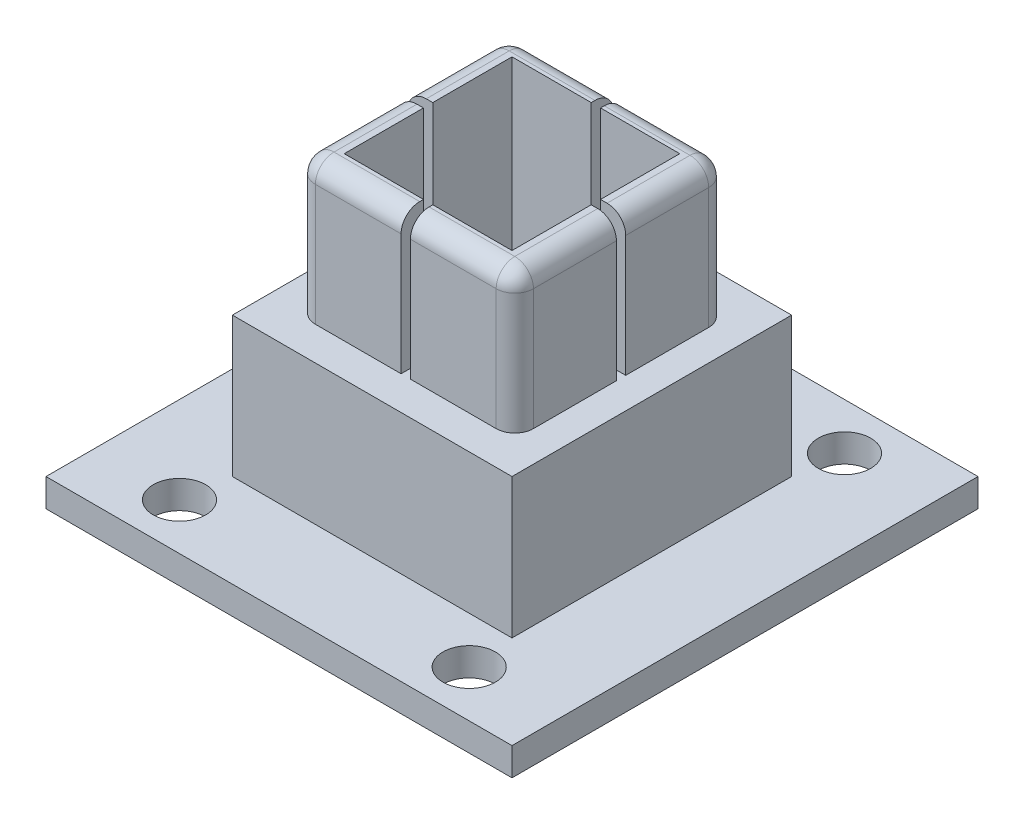
from build123d import *

# Parameters (mm, degrees)
CROQUIS1_W              = 50
CROQUIS1_H              = 50
SALIENTE_EXTRUIR1_DEPTH = 3
CROQUIS2_W              = 30
CROQUIS2_H              = 30
CROQUIS2_W_2            = 18
CROQUIS2_H_2            = 18
SALIENTE_EXTRUIR2_DEPTH = 30
CROQUIS3_R              = 2.813865728
CORTAR_EXTRUIR1_DEPTH   = 10
CROQUIS4_W              = 30
CROQUIS4_H              = 30
CROQUIS4_W_2            = 23.4
CROQUIS4_H_2            = 22.8
CORTAR_EXTRUIR2_DEPTH   = 15
REDONDEO1_R             = 2
CROQUIS5_W              = 18
CROQUIS5_H              = 18
CORTAR_EXTRUIR3_DEPTH   = 16
CROQUIS6_W              = 1
CROQUIS6_H              = 15.294109798
CORTAR_EXTRUIR4_DEPTH   = 37.7
CROQUIS7_W              = 1
CROQUIS7_H              = 15.234542974
CORTAR_EXTRUIR5_DEPTH   = 37.4


with BuildPart() as part:
    # Croquis1 → Saliente-Extruir1 (new body)
    with BuildSketch(Plane(origin=(0, 0, 0), x_dir=(1, 0, 0), z_dir=(0, 1, 0))):
        Rectangle(CROQUIS1_W, CROQUIS1_H)
    extrude(amount=SALIENTE_EXTRUIR1_DEPTH)

    # Croquis2 → Saliente-Extruir2 (add)
    with BuildSketch(Plane(origin=(0, 3, 0), x_dir=(1, 0, 0), z_dir=(0, 1, 0))):
        Rectangle(CROQUIS2_W, CROQUIS2_H)
        Rectangle(CROQUIS2_W_2, CROQUIS2_H_2, mode=Mode.SUBTRACT)
    extrude(amount=SALIENTE_EXTRUIR2_DEPTH)

    # Croquis3 → Cortar-Extruir1 (cut)
    with BuildSketch(Plane(origin=(0, 3, 0), x_dir=(1, 0, 0), z_dir=(0, 1, 0))):
        with Locations((15.405421421, -20)):
            Circle(CROQUIS3_R)
        with Locations((-15.676153635, -20)):
            Circle(CROQUIS3_R)
        with Locations((15.676153635, 20)):
            Circle(CROQUIS3_R)
        with Locations((-15.676153635, 20)):
            Circle(CROQUIS3_R)
    extrude(amount=-CORTAR_EXTRUIR1_DEPTH, mode=Mode.SUBTRACT)

    # Croquis4 → Cortar-Extruir2 (cut)
    with BuildSketch(Plane(origin=(0, 33, 0), x_dir=(1, 0, 0), z_dir=(0, 1, 0))):
        Rectangle(CROQUIS4_W, CROQUIS4_H)
        Rectangle(CROQUIS4_W_2, CROQUIS4_H_2, mode=Mode.SUBTRACT)
    extrude(amount=-CORTAR_EXTRUIR2_DEPTH, mode=Mode.SUBTRACT)

    # Redondeo1
    redondeo1_edges = [part.edges().sort_by_distance(p)[0] for p in [
        (-11.7, 33, 0),
        (-11.7, 25.5, -11.4),
        (0, 33, -11.4),
        (11.7, 25.5, -11.4),
        (11.7, 33, 0),
        (11.7, 25.5, 11.4),
        (0, 33, 11.4),
        (-11.7, 25.5, 11.4),
    ]]
    fillet(redondeo1_edges, radius=REDONDEO1_R)

    # Croquis5 → Cortar-Extruir3 (cut)
    with BuildSketch(Plane.XZ):
        Rectangle(CROQUIS5_W, CROQUIS5_H)
    extrude(amount=-CORTAR_EXTRUIR3_DEPTH, mode=Mode.SUBTRACT)

    # Croquis6 → Cortar-Extruir4 (cut, through all)
    with BuildSketch(Plane.ZY.offset(11.7)):
        with Locations((0, 25.647054899)):
            Rectangle(CROQUIS6_W, CROQUIS6_H)
    extrude(amount=-CORTAR_EXTRUIR4_DEPTH, mode=Mode.SUBTRACT)

    # Croquis7 → Cortar-Extruir5 (cut, through all)
    with BuildSketch(Plane.XY.offset(11.4)):
        with Locations((0, 25.617271487)):
            Rectangle(CROQUIS7_W, CROQUIS7_H)
    extrude(amount=-CORTAR_EXTRUIR5_DEPTH, mode=Mode.SUBTRACT)


solid = part.part
